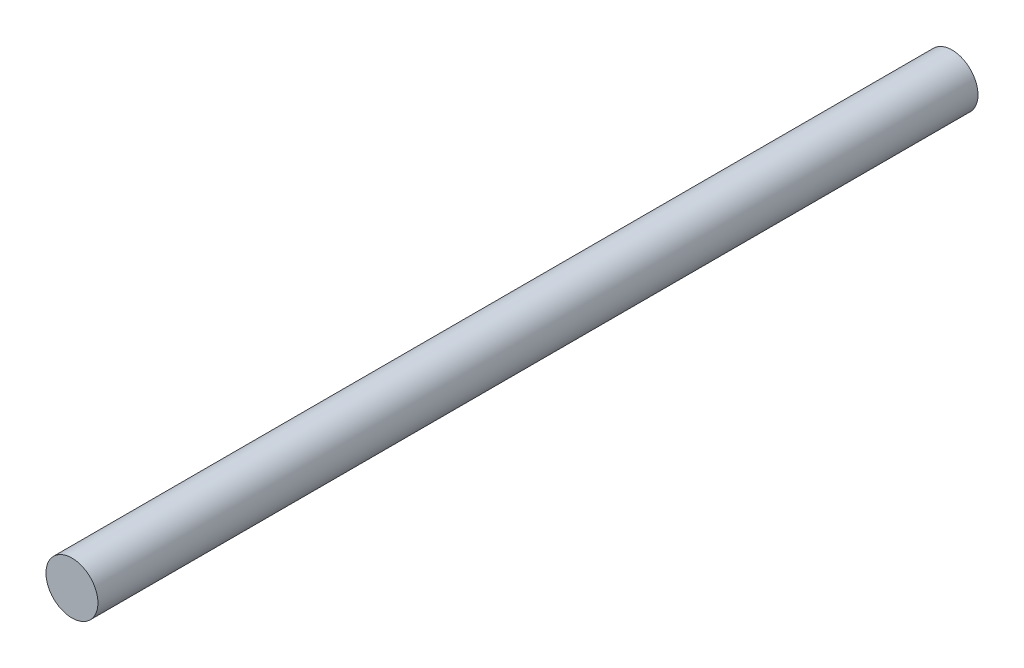
from build123d import *

# Parameters (mm, degrees)
SKETCH2_R           = 3
BOSS_EXTRUDE1_DEPTH = 101.6


with BuildPart() as part:
    # Sketch2 → Boss-Extrude1 (new body)
    with BuildSketch(Plane.XY):
        Circle(SKETCH2_R)
    extrude(amount=BOSS_EXTRUDE1_DEPTH)


solid = part.part
